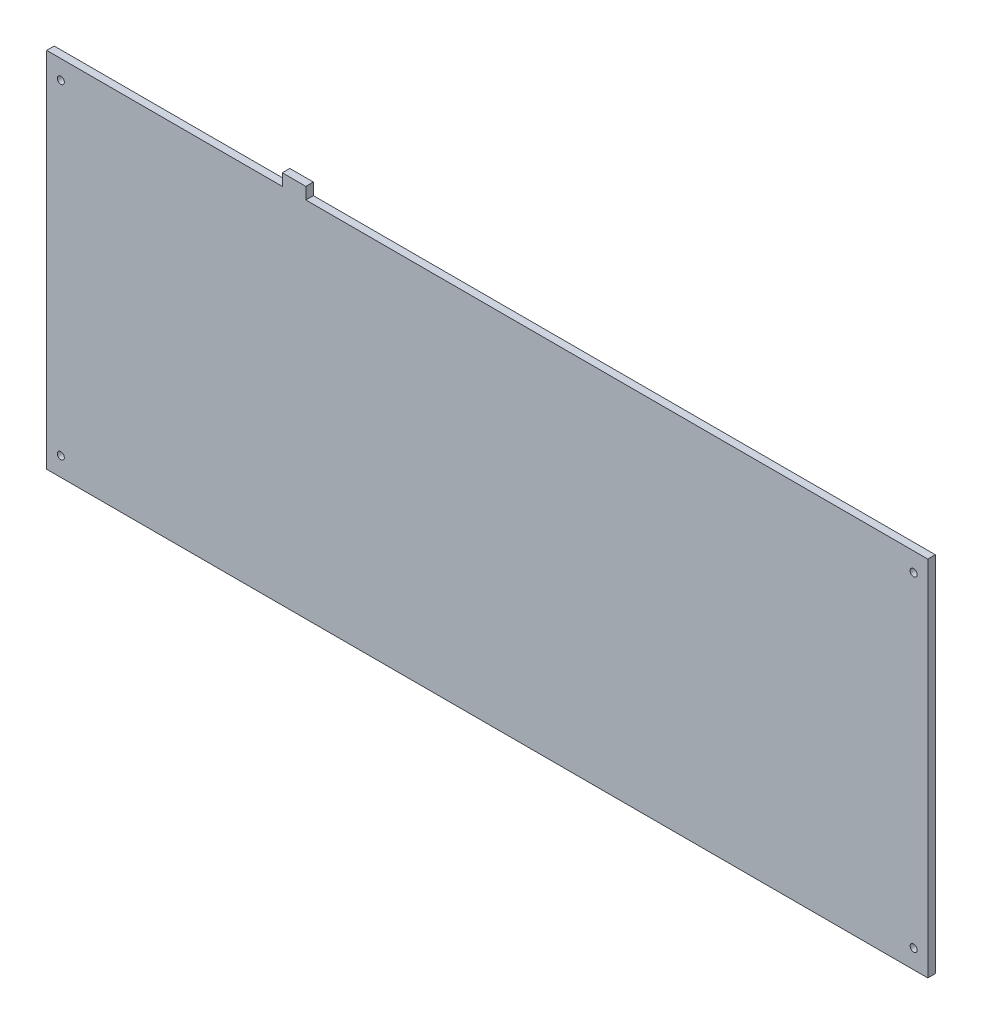
from build123d import *

# Parameters (mm, degrees)
KEEPOUTLAYER_W      = 186.9999816
KEEPOUTLAYER_H      = 76.9999984
EXTRUDE_1_DEPTH     = 1.6
VIAHOLELAYER_R      = 0.7499985
CUT_EXTRUDE_1_DEPTH = 2.6
SKETCH_2_W          = 5
SKETCH_2_H          = 1.6
EXTRUDE_3_DEPTH     = 2.5


with BuildPart() as part:
    # KeepOutLayer → Бобышка-Вытянуть1 (new body)
    with BuildSketch(Plane.XY):
        with Locations((93.56941662, -38.56797722)):
            Rectangle(KEEPOUTLAYER_W, KEEPOUTLAYER_H)
    extrude(amount=-EXTRUDE_1_DEPTH)

    # ViaHoleLayer → Вырез-Вытянуть1 (cut, through all)
    with BuildSketch(Plane.XY):
        with Locations((3.0693995, -73.06799966)):
            Circle(VIAHOLELAYER_R)
        with Locations((3.0693995, -4.0680005)):
            Circle(VIAHOLELAYER_R)
        with Locations((184.06940072, -73.06799966)):
            Circle(VIAHOLELAYER_R)
        with Locations((184.06940072, -4.0680005)):
            Circle(VIAHOLELAYER_R)
    extrude(amount=-CUT_EXTRUDE_1_DEPTH, mode=Mode.SUBTRACT)

    # Эскиз2 → Бобышка-Вытянуть3 (add)
    with BuildSketch(Plane(origin=(0, -0.06797802, 0), x_dir=(1, 0, 0), z_dir=(0, 1, 0))):
        with Locations((52.56942582, 0.8)):
            Rectangle(SKETCH_2_W, SKETCH_2_H)
    extrude(amount=EXTRUDE_3_DEPTH)


solid = part.part
